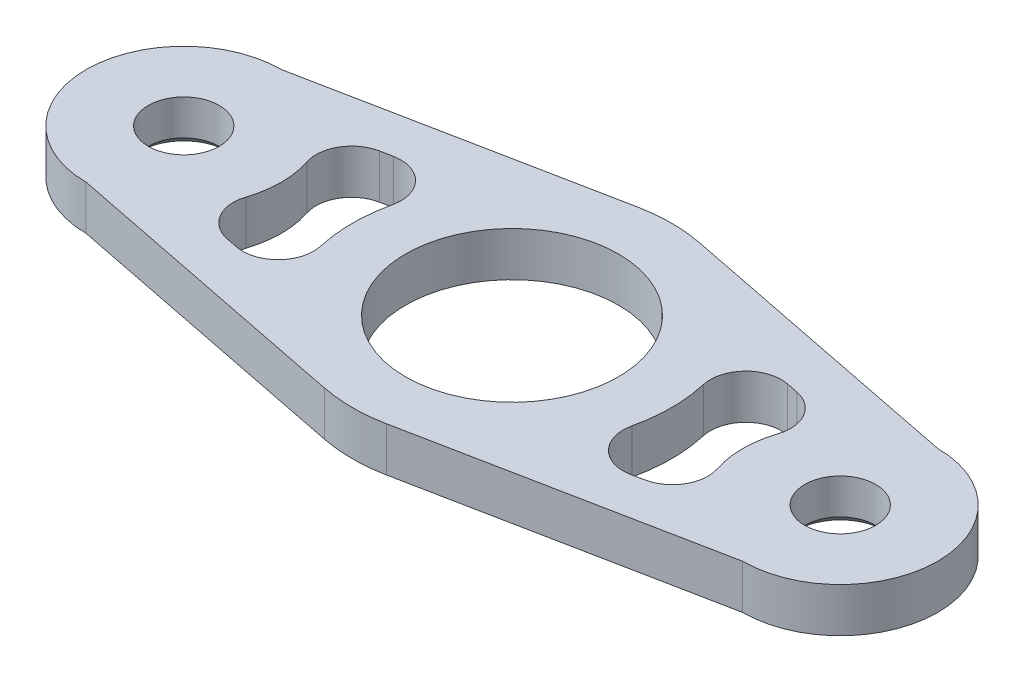
from build123d import *

# Parameters (mm, degrees)
SKETCH1_R           = 4
SKETCH1_R_2         = 12
BOSS_EXTRUDE1_DEPTH = 2.5
FILLET1_R           = 4
CHAMFER1_SIZE       = 1


with BuildPart() as part:
    # Sketch1 → Boss-Extrude1 (new body, symmetric)
    with BuildSketch(Plane(origin=(0, 0, 0), x_dir=(1, 0, 0), z_dir=(0, 1, 0))):
        with BuildLine():
            Line((37, 11), (3.508016814, 17.654852535))
            ThreePointArc((3.508016814, 17.654852535), (0, 18), (-3.508016814, 17.654852535))
            Line((-3.508016814, 17.654852535), (-37, 11))
            ThreePointArc((-37, 11), (-48, 0), (-37, -11))
            Line((-37, -11), (-3.508016814, -17.654852535))
            ThreePointArc((-3.508016814, -17.654852535), (0, -18), (3.508016814, -17.654852535))
            Line((3.508016814, -17.654852535), (37, -11))
            ThreePointArc((37, -11), (48, 0), (37, 11))
        make_face()
        with Locations((37, 0)):
            Circle(SKETCH1_R, mode=Mode.SUBTRACT)
        with Locations((-37, 0)):
            Circle(SKETCH1_R, mode=Mode.SUBTRACT)
        Circle(SKETCH1_R_2, mode=Mode.SUBTRACT)
        with BuildLine():
            Line((-28.954155956, -7.500959513), (-14.744742226, -10.324368102))
            ThreePointArc((-14.744742226, -10.324368102), (-18, 0), (-14.744742226, 10.324368102))
            Line((-14.744742226, 10.324368102), (-28.954155956, 7.500959513))
            ThreePointArc((-28.954155956, 7.500959513), (-26, 0), (-28.954155956, -7.500959513))
        make_face(mode=Mode.SUBTRACT)
        with BuildLine():
            ThreePointArc((14.744742226, 10.324368102), (18, 0), (14.744742226, -10.324368102))
            Line((14.744742226, -10.324368102), (28.954155956, -7.500959513))
            ThreePointArc((28.954155956, -7.500959513), (26, 0), (28.954155956, 7.500959513))
            Line((28.954155956, 7.500959513), (14.744742226, 10.324368102))
        make_face(mode=Mode.SUBTRACT)
    extrude(amount=BOSS_EXTRUDE1_DEPTH, both=True)

    # Fillet1
    fillet1_edges = [part.edges().sort_by_distance(p)[0] for p in [
        (14.744742226, 0, 10.324368102),
        (28.954155956, 0, 7.500959513),
        (28.954155956, 0, -7.500959513),
        (14.744742226, 0, -10.324368102),
        (-14.744742226, 0, 10.324368102),
        (-14.744742226, 0, -10.324368102),
        (-28.954155956, 0, -7.500959513),
        (-28.954155956, 0, 7.500959513),
    ]]
    fillet(fillet1_edges, radius=FILLET1_R)

    # Chamfer1
    chamfer1_edges = [part.edges().sort_by_distance(p)[0] for p in [
        (-41, -2.5, 0),
        (33, -2.5, 0),
    ]]
    chamfer(chamfer1_edges, length=CHAMFER1_SIZE)


solid = part.part
